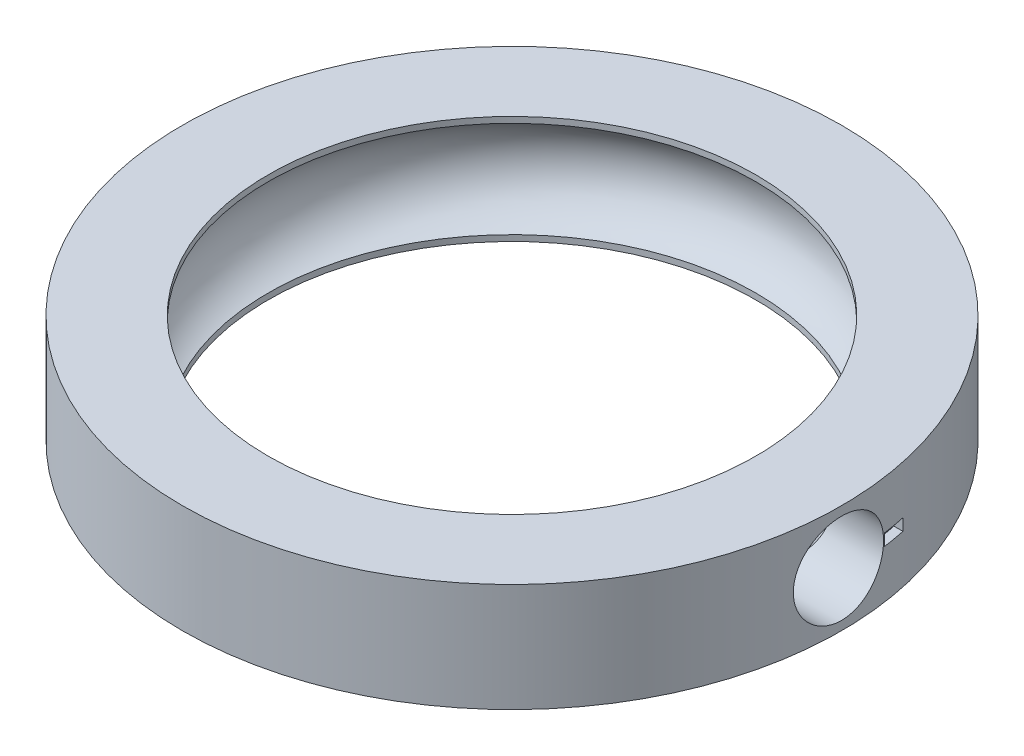
from build123d import *

# Parameters (mm, degrees)
SKETCH1_R                 = 18.25
SKETCH1_R_2               = 13.5
BOSS_EXTRUDE1_DEPTH       = 6
SKETCH3_R                 = 2.85
SKETCH4_R                 = 2.5
CUT_EXTRUDE1_DEPTH        = 27.497641404
CUT_EXTRUDE1_DEPTH_BACK   = 10
CUT_EXTRUDE2_REACH        = 28.998
CUT_EXTRUDE2_START_RADIUS = 18.25
CUT_EXTRUDE2_END_RADIUS   = 18.25
SKETCH6_W                 = 1.240344628
SKETCH6_H                 = 0.651674146


with BuildPart() as part:
    # Sketch1 → Boss-Extrude1 (new body)
    with BuildSketch(Plane(origin=(0, 0, 0), x_dir=(1, 0, 0), z_dir=(0, 1, 0))):
        with Locations(Location((0, 0, 0), (0, 0, 270))):
            Circle(SKETCH1_R)
        with Locations(Location((0, 0, 0), (0, 0, 270))):
            Circle(SKETCH1_R_2, mode=Mode.SUBTRACT)
    extrude(amount=BOSS_EXTRUDE1_DEPTH)

    # Sketch3 → Cut-Revolve1 (revolve, cut)
    with BuildSketch(Plane.XY, mode=Mode.PRIVATE) as cut_revolve1_sk:
        with Locations((-12.5, 3)):
            Circle(SKETCH3_R)
    revolve(cut_revolve1_sk.sketch.rotate(Axis((0, 0, 0), (0, 1, 0)), 270), axis=Axis((0, 0, 0), (0, 1, 0)), mode=Mode.SUBTRACT)

    # Sketch4 → Cut-Extrude1 (cut, two sides)
    with BuildSketch(Plane(origin=(0, 0, 0), x_dir=(0, 0, -1), z_dir=(1, 0, 0))) as cut_extrude1_sk:
        with Locations(Location((0, 3, 0), (0, 0, 267.756136347))):
            Circle(SKETCH4_R)
    extrude(amount=CUT_EXTRUDE1_DEPTH, mode=Mode.SUBTRACT)
    extrude(cut_extrude1_sk.sketch, amount=-CUT_EXTRUDE1_DEPTH_BACK, mode=Mode.SUBTRACT)

    # Cut-Extrude2: from a cylinder face, 28.998 long prism both ways, kept between that surface and its translate by the depth
    cut_extrude2_start = Plane(origin=(0, 3, 0), z_dir=(0, -1, 0)) * Cylinder(CUT_EXTRUDE2_START_RADIUS, 95.496, mode=Mode.PRIVATE)
    cut_extrude2_end = Plane(origin=(-0.5, 3, 0), z_dir=(0, -1, 0)) * Cylinder(CUT_EXTRUDE2_END_RADIUS, 95.496, mode=Mode.PRIVATE)
    # Sketch6 → Cut-Extrude2 (cut, from a surface)
    with BuildSketch(Plane(origin=(0, 0, 0), x_dir=(0, 0, -1), z_dir=(1, 0, 0)), mode=Mode.PRIVATE) as cut_extrude2_sk1:
        with Locations((3.176747556, 3)):
            Rectangle(SKETCH6_W, SKETCH6_H)
    cut_extrude2_tool1 = extrude(cut_extrude2_sk1.sketch, amount=CUT_EXTRUDE2_REACH, both=True, mode=Mode.PRIVATE)
    add(((cut_extrude2_tool1 & cut_extrude2_start) - cut_extrude2_end).solids().sort_by_distance((17.710349, 3, -3.176748))[0], mode=Mode.SUBTRACT)


solid = part.part
